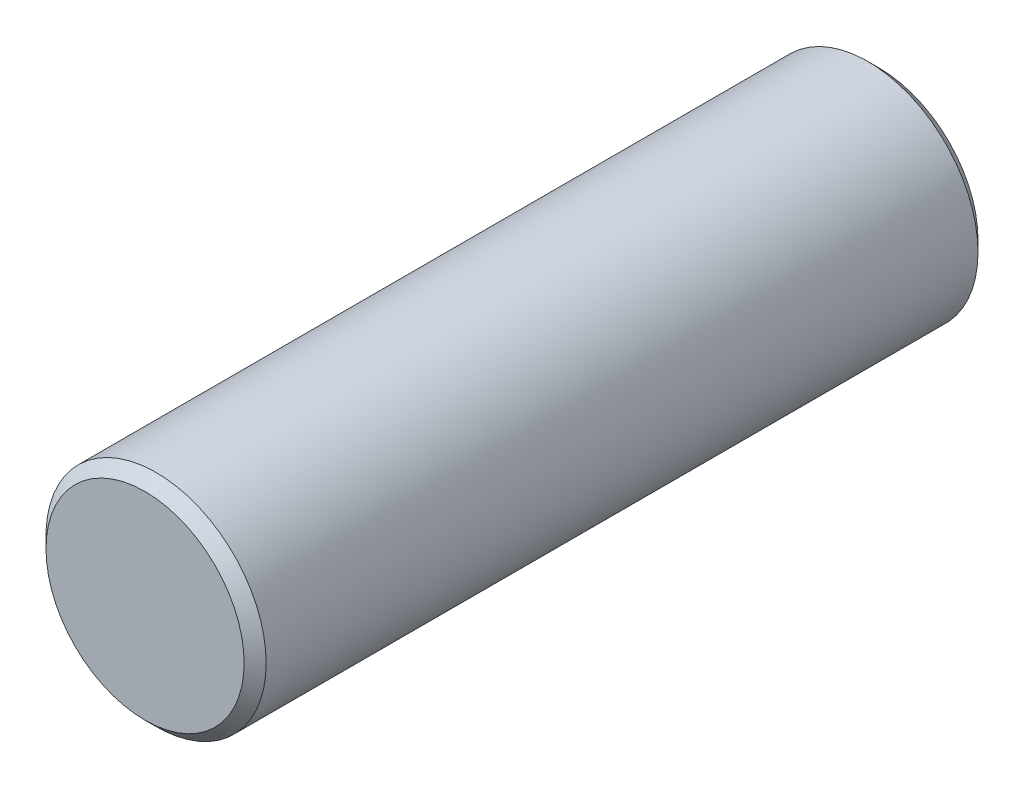
from build123d import *

# Parameters (mm, degrees)
ESTRUSIONE_ESTRUSIONE1_DEPTH      = 5
ESTRUSIONE_ESTRUSIONE1_DEPTH_BACK = 5
SCHIZZO1_R                        = 1.5
SMUSSO1_SIZE                      = 0.15


with BuildPart() as part:
    # Schizzo1 → Estrusione-Estrusione1 (new, two sides: drawn at the far end of the back side and taken through both)
    with BuildSketch(Plane.XY.offset(-ESTRUSIONE_ESTRUSIONE1_DEPTH_BACK)):
        Circle(SCHIZZO1_R)
    extrude(amount=ESTRUSIONE_ESTRUSIONE1_DEPTH + ESTRUSIONE_ESTRUSIONE1_DEPTH_BACK)

    # Smusso1
    smusso1_edges = [part.edges().sort_by_distance(p)[0] for p in [
        (-1.5, 0, 5),
        (-1.5, 0, -5),
    ]]
    chamfer(smusso1_edges, length=SMUSSO1_SIZE)


solid = part.part
